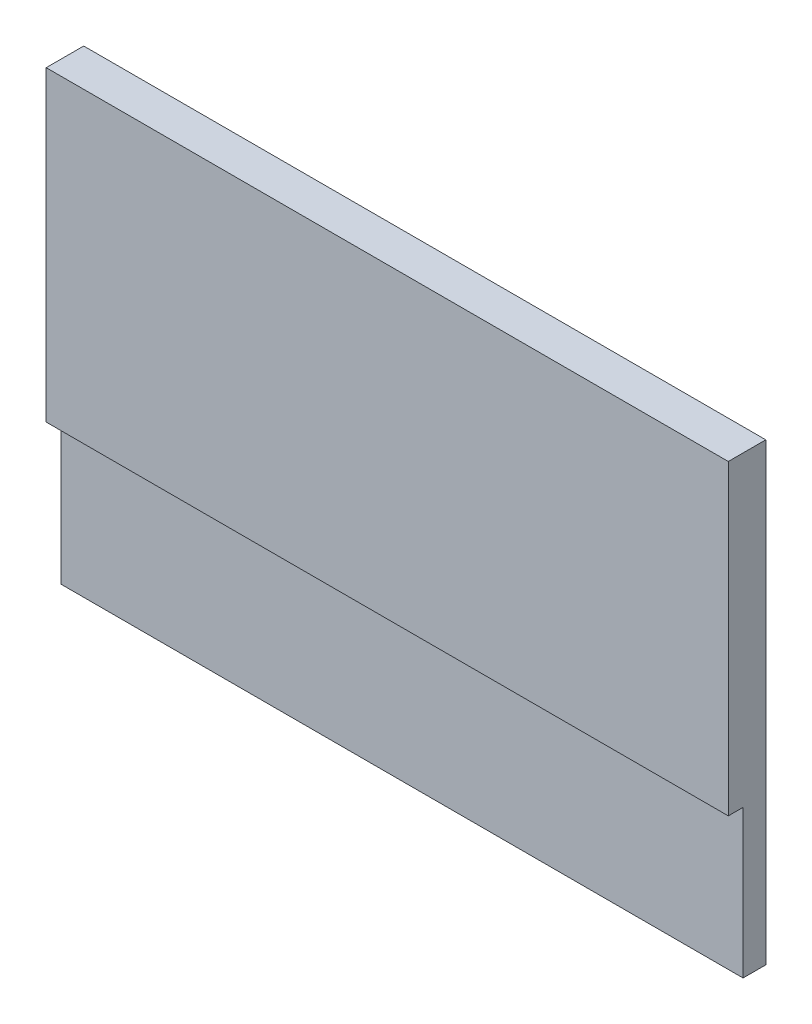
from build123d import *

# Parameters (mm, degrees)
SKETCH_1_W          = 30
SKETCH_1_H          = 20
EXTRUDE_1_DEPTH     = 1.65
SKETCH_2_W          = 30
SKETCH_2_H          = 6.5
CUT_EXTRUDE_1_DEPTH = 0.65


with BuildPart() as part:
    # ｽｹｯﾁ1 → ﾎﾞｽ - 押し出し1 (new body)
    with BuildSketch(Plane.XY):
        with Locations((15, 10)):
            Rectangle(SKETCH_1_W, SKETCH_1_H)
    extrude(amount=EXTRUDE_1_DEPTH)

    # ｽｹｯﾁ2 → ｶｯﾄ - 押し出し1 (cut)
    with BuildSketch(Plane.XY.offset(1.65)):
        with Locations((15, 3.25)):
            Rectangle(SKETCH_2_W, SKETCH_2_H)
    extrude(amount=-CUT_EXTRUDE_1_DEPTH, mode=Mode.SUBTRACT)


solid = part.part
